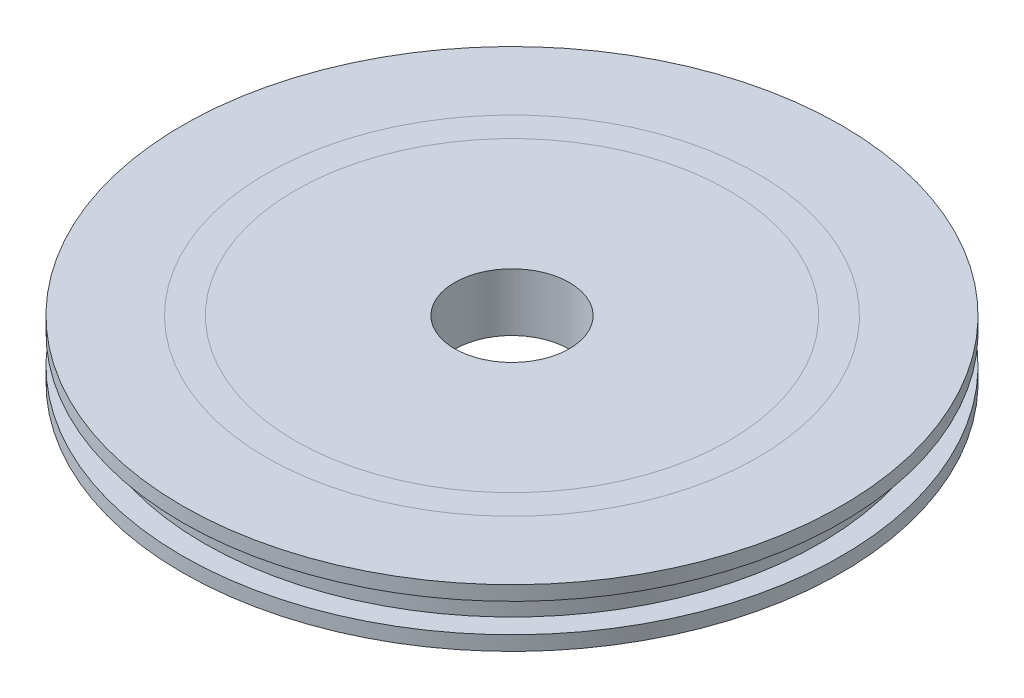
from build123d import *

# Parameters (mm, degrees)
SKETCH6_R          = 5.0419
CUT_EXTRUDE1_DEPTH = 6.08


with BuildPart() as part:
    # Sketch1 → Revolve1 (revolve)
    with BuildSketch(Plane(origin=(0, 0, 0), x_dir=(0, 0, -1), z_dir=(1, 0, 0))):
        Polygon((0, 0), (0, -5.08), (-28.956, -5.08), (-28.956, -3.81), (-27.051, -3.81), (-27.051, -1.27), (-28.956, -1.27), (-28.956, 0), align=None)
    revolve(axis=Axis((0, 0, 0), (0, -1, 0)))

    # Sketch6 → Cut-Extrude1 (cut, through all)
    with BuildSketch(Plane.XZ.offset(5.08)):
        Circle(SKETCH6_R)
    extrude(amount=-CUT_EXTRUDE1_DEPTH, mode=Mode.SUBTRACT)


solid = part.part
